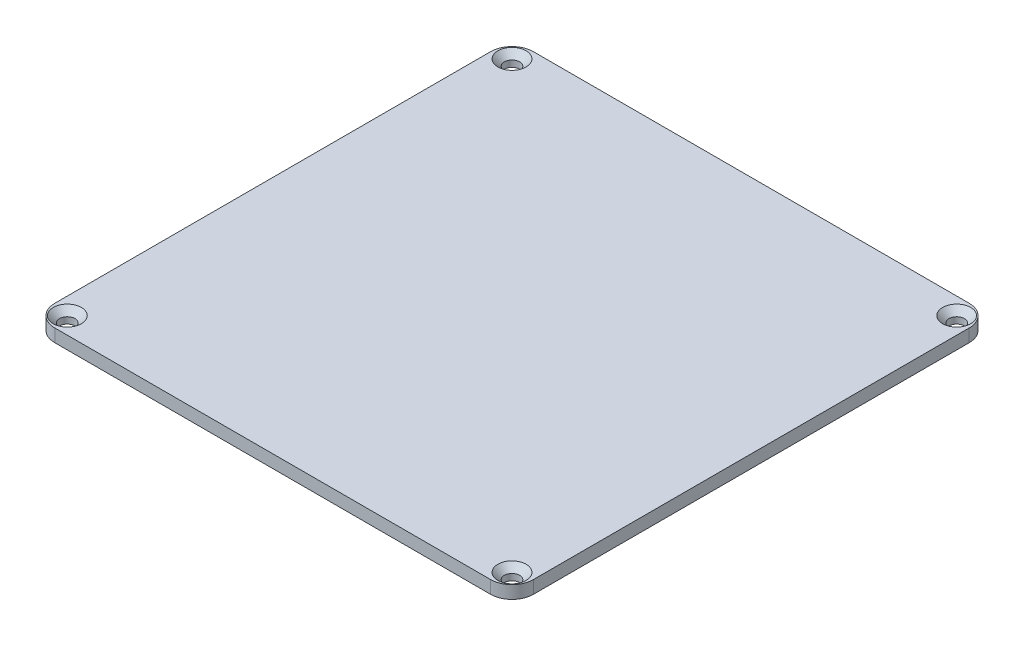
from build123d import *

# Parameters (mm, degrees)
SKETCH_1_W                  = 112
SKETCH_1_H                  = 112
EXTRUDE_1_DEPTH             = 3
HOLE_WIZARD_M3_5_AT_2_COUNT = 2
HOLE_WIZARD_M3_5_AT_2_PITCH = 147.177205436
HOLE_WIZARD_M3_5_AT_3_COUNT = 2
HOLE_WIZARD_M3_5_AT_3_PITCH = 104.07
HOLE_WIZARD_M3_5_AT_4_COUNT = 2
HOLE_WIZARD_M3_5_AT_4_PITCH = 104.07
FILLET_1_R                  = 5


with BuildPart() as part:
    # 草图1 → 凸台-拉伸1 (new body)
    with BuildSketch(Plane(origin=(0, 0, 0), x_dir=(1, 0, 0), z_dir=(0, 1, 0))):
        Rectangle(SKETCH_1_W, SKETCH_1_H)
    extrude(amount=EXTRUDE_1_DEPTH)

    # 草图20 → M3 十字槽半沉头木螺钉的锥形沉头孔5 (revolve, cut)
    with BuildSketch(Plane(origin=(52.035, 3, 52.035), x_dir=(0, 0, 1), z_dir=(1, 0, 0))):
        Polygon((0, 0), (0, 3), (1.8, 3), (1.8, 1.5), (3.3, 0), align=None)
    hole_wizard_m3_5 = revolve(axis=Axis((52.035, 9.35, 52.035), (0, -1, 0)), mode=Mode.SUBTRACT)

    # M3 十字槽半沉头木螺钉的锥形沉头孔5 at 2: M3 十字槽半沉头木螺钉的锥形沉头孔5 ×2
    with Locations(*[Vector(-0.707106781, 0, -0.707106781) * (i * HOLE_WIZARD_M3_5_AT_2_PITCH) for i in range(1, HOLE_WIZARD_M3_5_AT_2_COUNT)]):
        add(hole_wizard_m3_5, mode=Mode.SUBTRACT)

    # M3 十字槽半沉头木螺钉的锥形沉头孔5 at 3: M3 十字槽半沉头木螺钉的锥形沉头孔5 ×2
    with Locations(*[(-i * HOLE_WIZARD_M3_5_AT_3_PITCH, 0, 0) for i in range(1, HOLE_WIZARD_M3_5_AT_3_COUNT)]):
        add(hole_wizard_m3_5, mode=Mode.SUBTRACT)

    # M3 十字槽半沉头木螺钉的锥形沉头孔5 at 4: M3 十字槽半沉头木螺钉的锥形沉头孔5 ×2
    with Locations(*[(0, 0, -i * HOLE_WIZARD_M3_5_AT_4_PITCH) for i in range(1, HOLE_WIZARD_M3_5_AT_4_COUNT)]):
        add(hole_wizard_m3_5, mode=Mode.SUBTRACT)

    # 圆角1
    fillet_1_edges = [part.edges().sort_by_distance(p)[0] for p in [
        (56, 1.5, 56),
        (-56, 1.5, 56),
        (-56, 1.5, -56),
        (56, 1.5, -56),
    ]]
    fillet(fillet_1_edges, radius=FILLET_1_R)


solid = part.part
